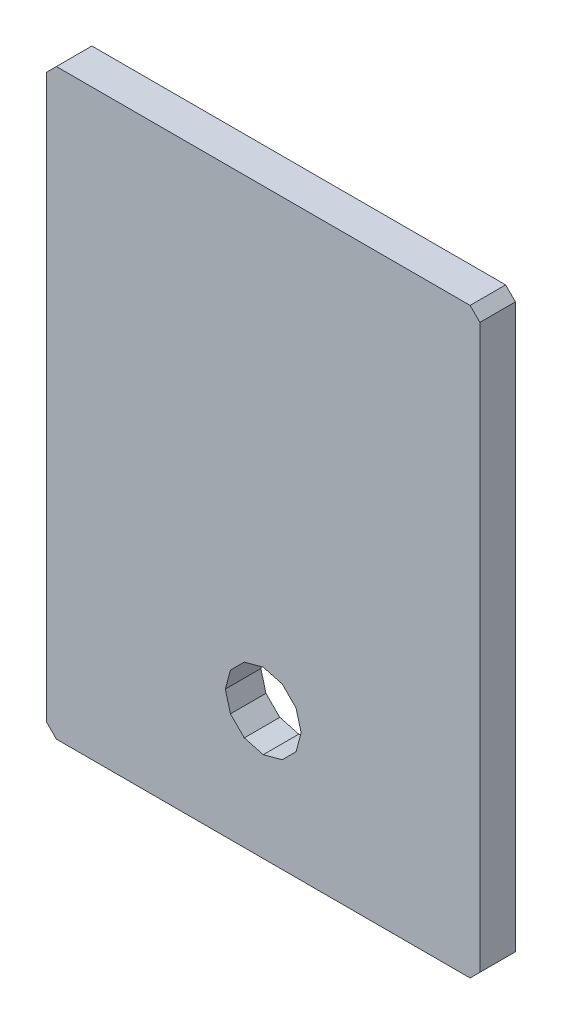
from build123d import *

# Parameters (mm, degrees)
EXTRUDE_3_DEPTH = 1.5


with BuildPart() as part:
    # Эскиз2 → Бобышка-Вытянуть3 (new body)
    with BuildSketch(Plane(origin=(0, 0, 0), x_dir=(-1, 0, 0), z_dir=(0, 0, 1))):
        Polygon((9.15, -11.885786438), (9.15, 11.885786438), (8.735786438, 12.3), (-8.735786438, 12.3), (-9.15, 11.885786438), (-9.15, -11.885786438), (-8.735786438, -12.3), (8.735786438, -12.3), align=None)
        Polygon((0, 8.5), (-0.8, 8.285640646), (-1.385640646, 7.7), (-1.6, 6.9), (-1.385640646, 6.1), (-0.8, 5.514359354), (0, 5.3), (0.8, 5.514359354), (1.385640646, 6.1), (1.6, 6.9), (1.385640646, 7.7), (0.8, 8.285640646), align=None, mode=Mode.SUBTRACT)
    extrude(amount=EXTRUDE_3_DEPTH)


solid = part.part
